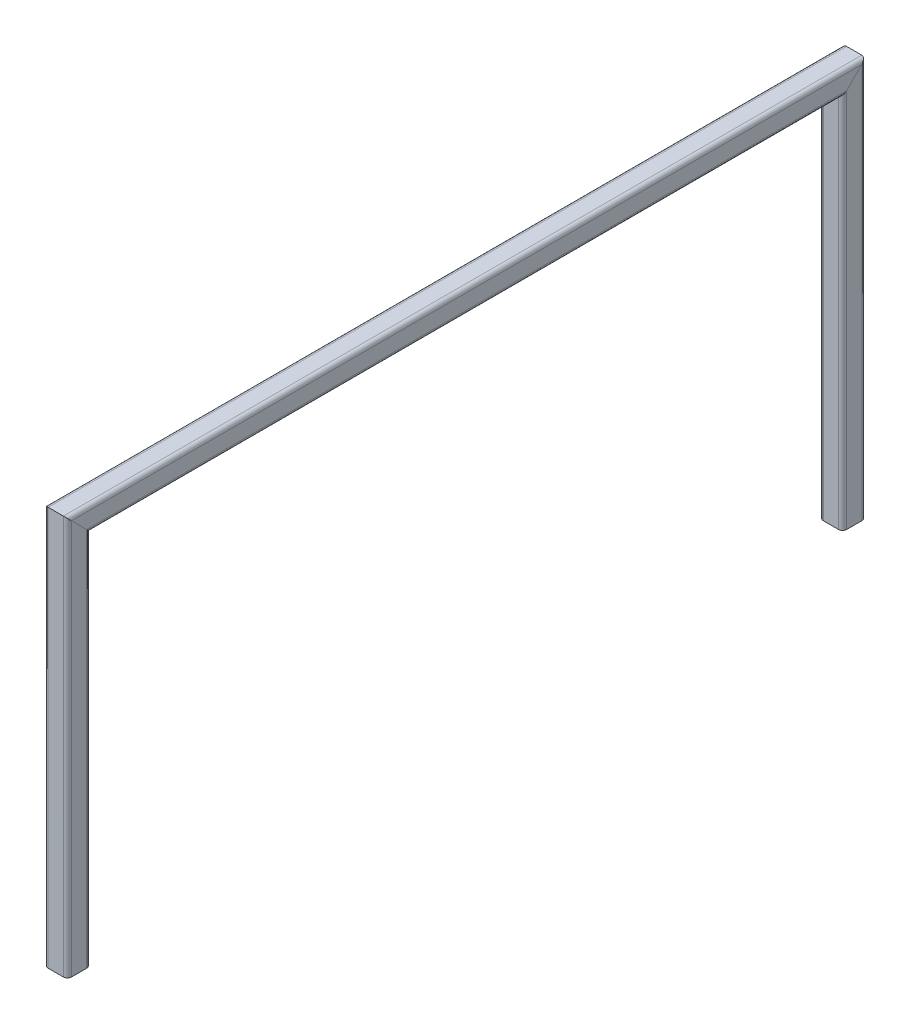
from build123d import *

# Parameters (mm, degrees)
SQUARE_TUBE_30_X_30_X_2_6_1_DEPTH        = 522.213203436
SQUARE_TUBE_30_X_30_X_2_6_1_2_DEPTH      = 1044.426406871
SQUARE_TUBE_30_X_30_X_2_6_1_3_DEPTH      = 500
SQUARE_TUBE_30_X_30_X_2_6_1_3_DEPTH_BACK = 22.213203436


with BuildPart() as part:
    # Sketch18 on segment 1 (carried to segment 1) → Square tube 30 X 30 X 2.6(1) (new body)
    with BuildSketch(Plane(origin=(0, -250, 500), x_dir=(0, 0, 1), z_dir=(0, 1, 0))):
        with BuildLine():
            Line((-9.8, -15), (9.8, -15))
            ThreePointArc((9.8, -15), (13.476955262, -13.476955262), (15, -9.8))
            Line((15, -9.8), (15, 9.8))
            ThreePointArc((15, 9.8), (13.476955262, 13.476955262), (9.8, 15))
            Line((9.8, 15), (-9.8, 15))
            ThreePointArc((-9.8, 15), (-13.476955262, 13.476955262), (-15, 9.8))
            Line((-15, 9.8), (-15, -9.8))
            ThreePointArc((-15, -9.8), (-13.476955262, -13.476955262), (-9.8, -15))
        make_face()
        with BuildLine():
            Line((-9.8, -12.4), (9.8, -12.4))
            ThreePointArc((9.8, -12.4), (11.638477631, -11.638477631), (12.4, -9.8))
            Line((12.4, -9.8), (12.4, 9.8))
            ThreePointArc((12.4, 9.8), (11.638477631, 11.638477631), (9.8, 12.4))
            Line((9.8, 12.4), (-9.8, 12.4))
            ThreePointArc((-9.8, 12.4), (-11.638477631, 11.638477631), (-12.4, 9.8))
            Line((-12.4, 9.8), (-12.4, -9.8))
            ThreePointArc((-12.4, -9.8), (-11.638477631, -11.638477631), (-9.8, -12.4))
        make_face(mode=Mode.SUBTRACT)
    extrude(amount=SQUARE_TUBE_30_X_30_X_2_6_1_DEPTH)

    # Square tube 30 X 30 X 2.6(1) mitre 1
    split(bisect_by=Plane(origin=(0, 250, 500), x_dir=(1, 0, 0), z_dir=(0, -0.707106781, 0.707106781)), keep=Keep.TOP)


with BuildPart() as body_2:
    # Sketch18 on segment 2 (carried to segment 2) → Square tube 30 X 30 X 2.6_1 2 (new body)
    with BuildSketch(Plane(origin=(0, 250, 522.213203436), x_dir=(0, 1, 0), z_dir=(0, 0, -1))):
        with BuildLine():
            Line((-9.8, -15), (9.8, -15))
            ThreePointArc((9.8, -15), (13.476955262, -13.476955262), (15, -9.8))
            Line((15, -9.8), (15, 9.8))
            ThreePointArc((15, 9.8), (13.476955262, 13.476955262), (9.8, 15))
            Line((9.8, 15), (-9.8, 15))
            ThreePointArc((-9.8, 15), (-13.476955262, 13.476955262), (-15, 9.8))
            Line((-15, 9.8), (-15, -9.8))
            ThreePointArc((-15, -9.8), (-13.476955262, -13.476955262), (-9.8, -15))
        make_face()
        with BuildLine():
            Line((-9.8, -12.4), (9.8, -12.4))
            ThreePointArc((9.8, -12.4), (11.638477631, -11.638477631), (12.4, -9.8))
            Line((12.4, -9.8), (12.4, 9.8))
            ThreePointArc((12.4, 9.8), (11.638477631, 11.638477631), (9.8, 12.4))
            Line((9.8, 12.4), (-9.8, 12.4))
            ThreePointArc((-9.8, 12.4), (-11.638477631, 11.638477631), (-12.4, 9.8))
            Line((-12.4, 9.8), (-12.4, -9.8))
            ThreePointArc((-12.4, -9.8), (-11.638477631, -11.638477631), (-9.8, -12.4))
        make_face(mode=Mode.SUBTRACT)
    extrude(amount=SQUARE_TUBE_30_X_30_X_2_6_1_2_DEPTH)

    # Square tube 30 X 30 X 2.6_1 2 mitre 1
    split(bisect_by=Plane(origin=(0, 250, -500), x_dir=(-1, 0, 0), z_dir=(0, 0.707106781, 0.707106781)), keep=Keep.TOP)

    # Square tube 30 X 30 X 2.6_1 2 mitre 2
    split(bisect_by=Plane(origin=(0, 250, 500), x_dir=(-1, 0, 0), z_dir=(0, 0.707106781, -0.707106781)), keep=Keep.TOP)


with BuildPart() as body_3:
    # Sketch18 → Square tube 30 X 30 X 2.6_1 3 (new, two sides)
    with BuildSketch(Plane(origin=(0, 250, -500), x_dir=(0, 0, -1), z_dir=(0, -1, 0))) as square_tube_30_x_30_x_2_6_1_3_sk:
        with BuildLine():
            Line((-9.8, -15), (9.8, -15))
            ThreePointArc((9.8, -15), (13.476955262, -13.476955262), (15, -9.8))
            Line((15, -9.8), (15, 9.8))
            ThreePointArc((15, 9.8), (13.476955262, 13.476955262), (9.8, 15))
            Line((9.8, 15), (-9.8, 15))
            ThreePointArc((-9.8, 15), (-13.476955262, 13.476955262), (-15, 9.8))
            Line((-15, 9.8), (-15, -9.8))
            ThreePointArc((-15, -9.8), (-13.476955262, -13.476955262), (-9.8, -15))
        make_face()
        with BuildLine():
            Line((-9.8, -12.4), (9.8, -12.4))
            ThreePointArc((9.8, -12.4), (11.638477631, -11.638477631), (12.4, -9.8))
            Line((12.4, -9.8), (12.4, 9.8))
            ThreePointArc((12.4, 9.8), (11.638477631, 11.638477631), (9.8, 12.4))
            Line((9.8, 12.4), (-9.8, 12.4))
            ThreePointArc((-9.8, 12.4), (-11.638477631, 11.638477631), (-12.4, 9.8))
            Line((-12.4, 9.8), (-12.4, -9.8))
            ThreePointArc((-12.4, -9.8), (-11.638477631, -11.638477631), (-9.8, -12.4))
        make_face(mode=Mode.SUBTRACT)
    extrude(amount=SQUARE_TUBE_30_X_30_X_2_6_1_3_DEPTH)
    extrude(square_tube_30_x_30_x_2_6_1_3_sk.sketch, amount=-SQUARE_TUBE_30_X_30_X_2_6_1_3_DEPTH_BACK)

    # Square tube 30 X 30 X 2.6_1 3 mitre 1
    split(bisect_by=Plane(origin=(0, 250, -500), x_dir=(1, 0, 0), z_dir=(0, -0.707106781, -0.707106781)), keep=Keep.TOP)


solid = Compound([part.part, body_2.part, body_3.part])
